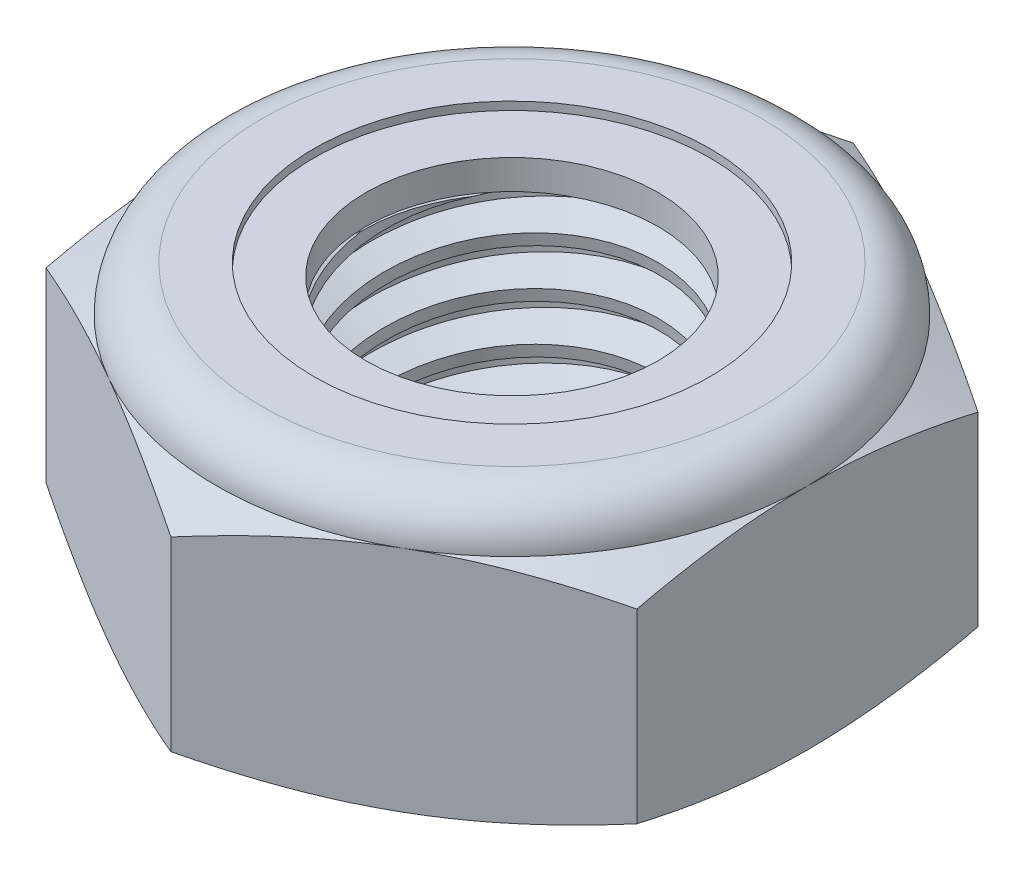
from build123d import *

# Parameters (mm, degrees)
EXTRUDE1_DEPTH      = 5.159375
SKETCH2_W           = 3.175
SKETCH2_H           = 5.159375
LPATTERN1_COUNT     = 6
LPATTERN1_PITCH     = 0.907142857
LPATTERN1_COL_COUNT = 2
LPATTERN1_COL_PITCH = 0.907142857


with BuildPart() as part:
    # Sketch1 → Extrude1 (new body)
    with BuildSketch(Plane(origin=(0, 0, 0), x_dir=(1, 0, 0), z_dir=(0, 1, 0))):
        Polygon((0, 6.415804866), (-5.55625, 3.207902433), (-5.55625, -3.207902433), (0, -6.415804866), (5.55625, -3.207902433), (5.55625, 3.207902433), align=None)
    extrude(amount=EXTRUDE1_DEPTH)

    # Sketch4 → Cut-Revolve2 (revolve, cut)
    with BuildSketch(Plane(origin=(0, 0, 0), x_dir=(0, 0, -1), z_dir=(1, 0, 0))):
        Polygon((0, 5.159375), (3.175, 5.159375), (2.74505598, 4.958888811), (2.74505598, 0.200486189), (3.175, 0), (0, 0), align=None)
    revolve(axis=Axis((0, 5.159375, 0), (0, 1, 0)), mode=Mode.SUBTRACT)


with BuildPart() as body_2:
    # Sketch2 → Revolve1 (revolve)
    with BuildSketch(Plane(origin=(0, 0, 0), x_dir=(0, 0, -1), z_dir=(1, 0, 0))):
        with Locations((1.5875, 2.5796875)):
            Rectangle(SKETCH2_W, SKETCH2_H)
    revolve(axis=Axis((0, -3.175, 0), (0, 1, 0)))

    # Sketch3 → Cut-Revolve1 (revolve, cut)
    with BuildSketch(Plane(origin=(0, 0, 0), x_dir=(0, 0, -1), z_dir=(1, 0, 0))):
        Polygon((3.191036172, 5.047121798), (3.303289373, 4.261349388), (2.777128323, 4.472543732), (2.74505598, 4.697050135), align=None)
    cut_revolve1 = revolve(axis=Axis((0, 5.159375, 0.1384314), (0, -0.989949494, -0.141421356)), mode=Mode.SUBTRACT)

    # LPattern1: Cut-Revolve1 ×6
    with Locations(*[(0, -i * LPATTERN1_PITCH, 0) for i in range(1, LPATTERN1_COUNT)]):
        add(cut_revolve1, mode=Mode.SUBTRACT)

    # LPattern1 col: Cut-Revolve1 ×2
    with Locations(*[(0, i * LPATTERN1_COL_PITCH, 0) for i in range(1, LPATTERN1_COL_COUNT)]):
        add(cut_revolve1, mode=Mode.SUBTRACT)


with BuildPart() as part_1:
    add(part.part)

    # Combine1: cut body 2
    add(body_2.part, mode=Mode.SUBTRACT)

    # Sketch5 → Cut-Revolve3 (revolve, cut)
    with BuildSketch(Plane(origin=(0, 0, 0), x_dir=(0, 0, -1), z_dir=(1, 0, 0))):
        with BuildLine():
            Line((0, 0), (5.55625, 0))
            Line((5.55625, 0), (6.415804866, 0.400817017))
            Line((6.415804866, 0.400817017), (6.415804866, 3.89866215))
            Line((6.415804866, 3.89866215), (5.55625, 4.299479167))
            ThreePointArc((5.55625, 4.299479167), (5.304392342, 4.907517342), (4.696354167, 5.159375))
            Line((4.696354167, 5.159375), (4.696354167, 6.429375))
            Line((4.696354167, 6.429375), (7.685804866, 6.429375))
            Line((7.685804866, 6.429375), (7.685804866, -1.27))
            Line((7.685804866, -1.27), (0, -1.27))
            Line((0, -1.27), (0, 0))
        make_face()
    revolve(axis=Axis((0, 0, 0), (0, 1, 0)), mode=Mode.SUBTRACT)

    # Sketch6 → Cut-Revolve4 (revolve, cut)
    with BuildSketch(Plane(origin=(0, 0, 0), x_dir=(0, 0, -1), z_dir=(1, 0, 0))):
        with BuildLine():
            Line((0, 4.299479167), (5.40385, 4.299479167))
            ThreePointArc((5.40385, 4.299479167), (5.196629268, 4.799754268), (4.696354167, 5.006975))
            Line((4.696354167, 5.006975), (3.720705073, 5.006975))
            Line((3.720705073, 5.006975), (3.720705073, 6.429375))
            Line((3.720705073, 6.429375), (0, 6.429375))
            Line((0, 6.429375), (0, 4.299479167))
        make_face()
    revolve(axis=Axis((0, 6.429375, 0), (0, 1, 0)), mode=Mode.SUBTRACT)


with BuildPart() as body_2_2:
    # Sketch7 → Revolve2 (revolve)
    with BuildSketch(Plane(origin=(0, 0, 0), x_dir=(0, 0, -1), z_dir=(1, 0, 0))):
        with BuildLine():
            Line((2.74505598, 4.375679167), (5.3230343, 4.375679167))
            ThreePointArc((5.3230343, 4.375679167), (5.114940888, 4.772046184), (4.696354167, 4.930775))
            Line((4.696354167, 4.930775), (2.74505598, 4.930775))
            Line((2.74505598, 4.930775), (2.74505598, 4.375679167))
        make_face()
    revolve(axis=Axis((0, 4.375679167, 0), (0, 1, 0)))


solid = Compound([part_1.part, body_2_2.part])
